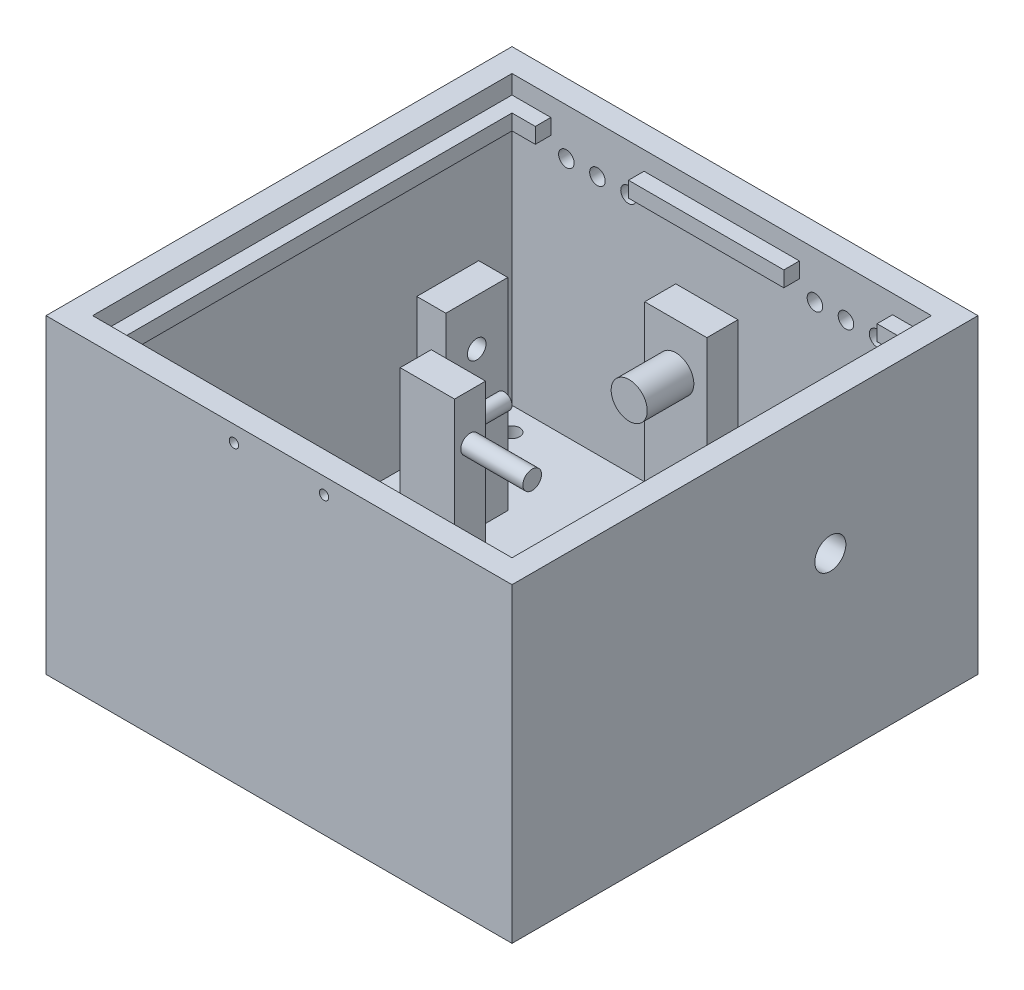
from build123d import *

# Parameters (mm, degrees)
SKETCH1_W            = 150
SKETCH1_H            = 150
BOSS_EXTRUDE1_DEPTH  = 7.5
SKETCH2_W            = 150
SKETCH2_H            = 150
SKETCH2_W_2          = 135
SKETCH2_H_2          = 135
BOSS_EXTRUDE2_DEPTH  = 92.5
SKETCH3_W            = 20
SKETCH3_H            = 10
BOSS_EXTRUDE3_DEPTH  = 65
SKETCH4_R            = 5.8075
BOSS_EXTRUDE4_DEPTH  = 15
SKETCH5_W            = 9.35632758
SKETCH5_H            = 19.933045712
BOSS_EXTRUDE5_DEPTH  = 65
SKETCH7_W            = 7.5
SKETCH7_H            = 5
SKETCH7_W_2          = 10
BOSS_EXTRUDE7_DEPTH  = 65
SKETCH8_R            = 2.5
BOSS_EXTRUDE8_DEPTH  = 17.5
SKETCH10_W           = 17.5
SKETCH10_H           = 5
BOSS_EXTRUDE10_DEPTH = 65
SKETCH12_R           = 3
BOSS_EXTRUDE11_DEPTH = 20
SKETCH6_R            = 3
CUT_EXTRUDE1_DEPTH   = 10
SKETCH13_W           = 16
SKETCH13_H           = 12
BOSS_EXTRUDE12_DEPTH = 12.5
SKETCH14_W           = 35
SKETCH14_H           = 41
BOSS_EXTRUDE13_DEPTH = 31
SKETCH15_R           = 5
CUT_EXTRUDE2_DEPTH   = 10
SKETCH16_W           = 150
SKETCH16_H           = 5
BOSS_EXTRUDE14_DEPTH = 5
SKETCH17_W           = 12.5
SKETCH17_H           = 5
SKETCH17_W_2         = 50
BOSS_EXTRUDE15_DEPTH = 5
SKETCH18_W           = 150
SKETCH18_H           = 5
BOSS_EXTRUDE16_DEPTH = 5
SKETCH19_W           = 150
SKETCH19_H           = 5
BOSS_EXTRUDE17_DEPTH = 5
SKETCH20_R           = 2.5
CUT_EXTRUDE3_DEPTH   = 10
SKETCH21_R           = 2.5
CUT_EXTRUDE4_DEPTH   = 10
SKETCH22_R           = 1.5
CUT_EXTRUDE5_DEPTH   = 5
SKETCH23_R           = 1
SKETCH23_R_2         = 0.6
CUT_EXTRUDE6_DEPTH   = 4
SKETCH24_R           = 0.75
SKETCH24_R_2         = 0.5
CUT_EXTRUDE7_DEPTH   = 4


with BuildPart() as part:
    # Sketch1 → Boss-Extrude1 (new body)
    with BuildSketch(Plane(origin=(0, 0, 0), x_dir=(1, 0, 0), z_dir=(0, 1, 0))):
        Rectangle(SKETCH1_W, SKETCH1_H)
    extrude(amount=BOSS_EXTRUDE1_DEPTH)

    # Sketch2 → Boss-Extrude2 (add)
    with BuildSketch(Plane(origin=(0, 7.5, 0), x_dir=(1, 0, 0), z_dir=(0, 1, 0))):
        Rectangle(SKETCH2_W, SKETCH2_H)
        Rectangle(SKETCH2_W_2, SKETCH2_H_2, mode=Mode.SUBTRACT)
    extrude(amount=BOSS_EXTRUDE2_DEPTH)

    # Sketch3 → Boss-Extrude3 (add)
    with BuildSketch(Plane(origin=(0, 7.5, 0), x_dir=(1, 0, 0), z_dir=(0, 1, 0))):
        with Locations((0, 57.724473197)):
            Rectangle(SKETCH3_W, SKETCH3_H)
    extrude(amount=BOSS_EXTRUDE3_DEPTH)

    # Sketch4 → Boss-Extrude4 (add)
    with BuildSketch(Plane.XY.offset(-52.724473197)):
        with Locations((0, 57.5)):
            Circle(SKETCH4_R)
    extrude(amount=BOSS_EXTRUDE4_DEPTH)

    # Sketch5 → Boss-Extrude5 (add)
    with BuildSketch(Plane(origin=(0, 7.5, 0), x_dir=(1, 0, 0), z_dir=(0, 1, 0))):
        with Locations((-43.5, 27.5)):
            Rectangle(SKETCH5_W, SKETCH5_H)
    extrude(amount=BOSS_EXTRUDE5_DEPTH)

    # Sketch7 → Boss-Extrude7 (add)
    with BuildSketch(Plane(origin=(0, 7.5, 0), x_dir=(1, 0, 0), z_dir=(0, 1, 0))):
        with Locations((-27.25, -2.5)):
            Rectangle(SKETCH7_W, SKETCH7_H)
        with Locations((-18.5, -2.5)):
            Rectangle(SKETCH7_W_2, SKETCH7_H)
    extrude(amount=BOSS_EXTRUDE7_DEPTH)

    # Sketch8 → Boss-Extrude8 (add)
    with BuildSketch(Plane(origin=(0, 0, 0), x_dir=(-1, 0, 0), z_dir=(0, 0, -1))):
        with Locations((20, 57.5)):
            Circle(SKETCH8_R)
    extrude(amount=BOSS_EXTRUDE8_DEPTH)

    # Sketch10 → Boss-Extrude10 (add)
    with BuildSketch(Plane(origin=(0, 7.5, 0), x_dir=(1, 0, 0), z_dir=(0, 1, 0))):
        with Locations((-22.25, 2.5)):
            Rectangle(SKETCH10_W, SKETCH10_H)
    extrude(amount=BOSS_EXTRUDE10_DEPTH)

    # Sketch12 → Boss-Extrude11 (add)
    with BuildSketch(Plane(origin=(-13.5, 0, 0), x_dir=(0, 0, -1), z_dir=(1, 0, 0))):
        with Locations((0, 57.5)):
            Circle(SKETCH12_R)
    extrude(amount=BOSS_EXTRUDE11_DEPTH)

    # Sketch6 → Cut-Extrude1 (cut)
    with BuildSketch(Plane(origin=(-38.82183621, 0, 0), x_dir=(0, 0, -1), z_dir=(1, 0, 0))):
        with Locations((27.466522856, 57.5)):
            Circle(SKETCH6_R)
    extrude(amount=-CUT_EXTRUDE1_DEPTH, mode=Mode.SUBTRACT)

    # Sketch13 → Boss-Extrude12 (add)
    with BuildSketch(Plane(origin=(0, 7.5, 0), x_dir=(1, 0, 0), z_dir=(0, 1, 0))):
        with Locations((26.2, 27.5)):
            Rectangle(SKETCH13_W, SKETCH13_H)
    extrude(amount=BOSS_EXTRUDE12_DEPTH)

    # Sketch14 → Boss-Extrude13 (add)
    with BuildSketch(Plane(origin=(0, 7.5, 0), x_dir=(1, 0, 0), z_dir=(0, 1, 0))):
        with Locations((47.5, 13)):
            Rectangle(SKETCH14_W, SKETCH14_H)
    extrude(amount=BOSS_EXTRUDE13_DEPTH)

    # Sketch15 → Cut-Extrude2 (cut)
    with BuildSketch(Plane(origin=(75, 0, 0), x_dir=(0, 0, -1), z_dir=(1, 0, 0))):
        with Locations((27.466523, 57.5)):
            Circle(SKETCH15_R)
    extrude(amount=-CUT_EXTRUDE2_DEPTH, mode=Mode.SUBTRACT)

    # Sketch16 → Boss-Extrude14 (add)
    with BuildSketch(Plane(origin=(0, 0, 67.5), x_dir=(-1, 0, 0), z_dir=(0, 0, -1))):
        with Locations((0, 91.5)):
            Rectangle(SKETCH16_W, SKETCH16_H)
    extrude(amount=BOSS_EXTRUDE14_DEPTH)

    # Sketch17 → Boss-Extrude15 (add)
    with BuildSketch(Plane.XY.offset(-67.5)):
        with Locations((-61.25, 91.5)):
            Rectangle(SKETCH17_W, SKETCH17_H)
        with Locations((0, 91.5)):
            Rectangle(SKETCH17_W_2, SKETCH17_H)
        with Locations((61.25, 91.5)):
            Rectangle(SKETCH17_W, SKETCH17_H)
    extrude(amount=BOSS_EXTRUDE15_DEPTH)

    # Sketch18 → Boss-Extrude16 (add)
    with BuildSketch(Plane.ZY.offset(-67.5)):
        with Locations((0, 91.5)):
            Rectangle(SKETCH18_W, SKETCH18_H)
    extrude(amount=BOSS_EXTRUDE16_DEPTH)

    # Sketch19 → Boss-Extrude17 (add)
    with BuildSketch(Plane(origin=(-67.5, 0, 0), x_dir=(0, 0, -1), z_dir=(1, 0, 0))):
        with Locations((0, 91.5)):
            Rectangle(SKETCH19_W, SKETCH19_H)
    extrude(amount=BOSS_EXTRUDE17_DEPTH)

    # Sketch20 → Cut-Extrude3 (cut)
    with BuildSketch(Plane(origin=(0, 0, -75), x_dir=(-1, 0, 0), z_dir=(0, 0, -1))):
        with Locations((-50, 85)):
            Circle(SKETCH20_R)
        with Locations((-40, 85)):
            Circle(SKETCH20_R)
        with Locations((-30, 85)):
            Circle(SKETCH20_R)
        with Locations((30, 85)):
            Circle(SKETCH20_R)
        with Locations((40, 85)):
            Circle(SKETCH20_R)
        with Locations((50, 85)):
            Circle(SKETCH20_R)
    extrude(amount=-CUT_EXTRUDE3_DEPTH, mode=Mode.SUBTRACT)

    # Sketch21 → Cut-Extrude4 (cut)
    with BuildSketch(Plane.XZ):
        with Locations((-60, 60)):
            Circle(SKETCH21_R)
        with Locations((60, 60)):
            Circle(SKETCH21_R)
        with Locations((-60, -60)):
            Circle(SKETCH21_R)
        with Locations((60, -60)):
            Circle(SKETCH21_R)
    extrude(amount=-CUT_EXTRUDE4_DEPTH, mode=Mode.SUBTRACT)

    # Sketch22 → Cut-Extrude5 (cut)
    with BuildSketch(Plane.XY.offset(75)):
        with Locations((-14.5, 94.75)):
            Circle(SKETCH22_R)
        with Locations((14.5, 94.75)):
            Circle(SKETCH22_R)
    extrude(amount=-CUT_EXTRUDE5_DEPTH, mode=Mode.SUBTRACT)

    # Sketch23 → Cut-Extrude6 (cut)
    with BuildSketch(Plane(origin=(0, 38.5, 0), x_dir=(1, 0, 0), z_dir=(0, 1, 0))):
        with Locations((32.5, 8.61)):
            Circle(SKETCH23_R)
        with Locations((32.5, 27.61)):
            Circle(SKETCH23_R)
        with Locations((63, 31.61)):
            Circle(SKETCH23_R_2)
        with Locations((57, 31.61)):
            Circle(SKETCH23_R_2)
        with Locations((57, 7.31)):
            Circle(SKETCH23_R_2)
        with Locations((63, 7.31)):
            Circle(SKETCH23_R_2)
        with Locations((57, 28.908369489)):
            Circle(SKETCH23_R_2)
        with Locations((63, 28.91)):
            Circle(SKETCH23_R_2)
        with Locations((63, 4.61)):
            Circle(SKETCH23_R_2)
        with Locations((57, 4.61)):
            Circle(SKETCH23_R_2)
    extrude(amount=-CUT_EXTRUDE6_DEPTH, mode=Mode.SUBTRACT)

    # Sketch24 → Cut-Extrude7 (cut)
    with BuildSketch(Plane(origin=(0, 20, 0), x_dir=(1, 0, 0), z_dir=(0, 1, 0))):
        with Locations((23.7, 24.466522856)):
            Circle(SKETCH24_R)
        with Locations((23.7, 30.5)):
            Circle(SKETCH24_R)
        with Locations((19.7, 31.716522856)):
            Circle(SKETCH24_R_2)
        with Locations((19.7, 23.2)):
            Circle(SKETCH24_R_2)
    extrude(amount=-CUT_EXTRUDE7_DEPTH, mode=Mode.SUBTRACT)


solid = part.part
